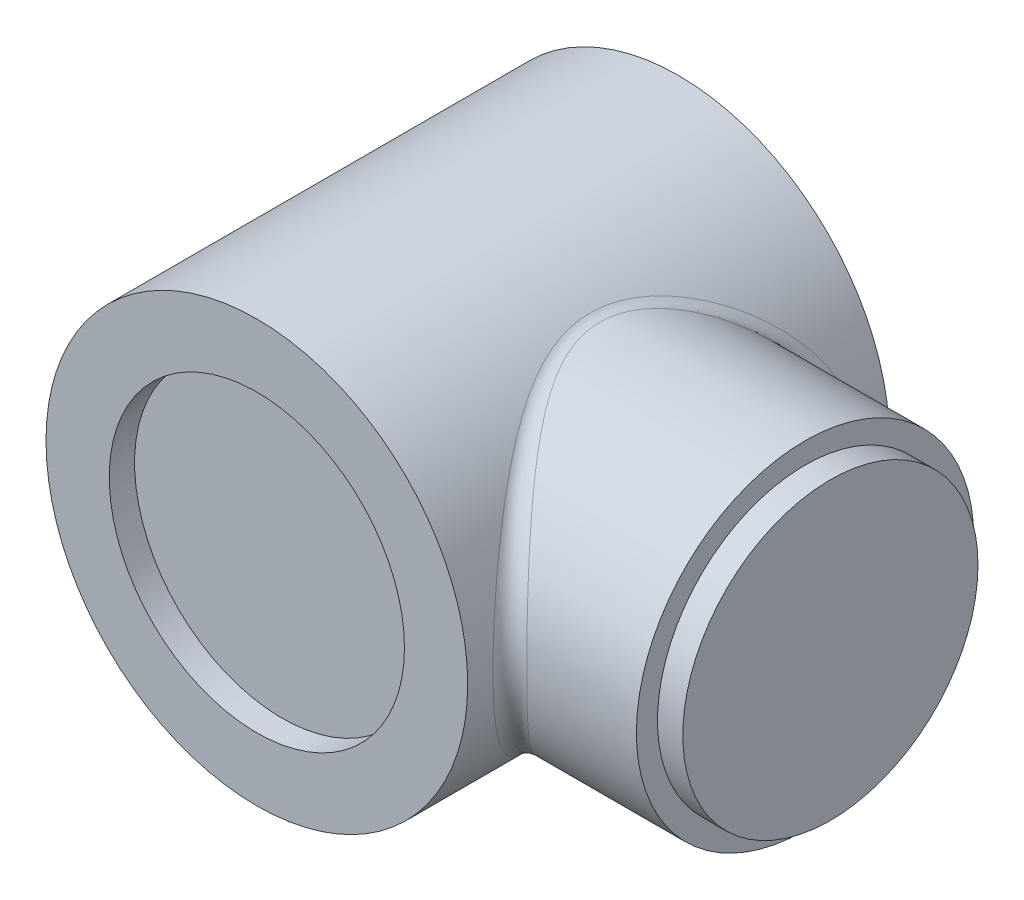
from build123d import *

# Parameters (mm, degrees)
SKETCH1_R           = 25
BOSS_EXTRUDE1_DEPTH = 25
SKETCH2_R           = 17.5
CUT_EXTRUDE1_DEPTH  = 3
SKETCH3_R           = 20
BOSS_EXTRUDE2_DEPTH = 40
SKETCH4_R           = 17.5
BOSS_EXTRUDE3_DEPTH = 3
FILLET1_R           = 2


with BuildPart() as part:
    # Sketch1 → Boss-Extrude1 (new body, symmetric)
    with BuildSketch(Plane.XY):
        Circle(SKETCH1_R)
    extrude(amount=BOSS_EXTRUDE1_DEPTH, both=True)

    # Sketch2 → Cut-Extrude1 (cut)
    with BuildSketch(Plane.XY.offset(25)):
        Circle(SKETCH2_R)
    cut_extrude1 = extrude(amount=-CUT_EXTRUDE1_DEPTH, mode=Mode.SUBTRACT)

    # Mirror1: Cut-Extrude1 across plane
    add(cut_extrude1.mirror(Plane.XY), mode=Mode.SUBTRACT)

    # Sketch3 → Boss-Extrude2 (add)
    with BuildSketch(Plane(origin=(0, 0, 0), x_dir=(0, 0, -1), z_dir=(1, 0, 0))):
        Circle(SKETCH3_R)
    extrude(amount=BOSS_EXTRUDE2_DEPTH)

    # Sketch4 → Boss-Extrude3 (add)
    with BuildSketch(Plane(origin=(40, 0, 0), x_dir=(0, 0, -1), z_dir=(1, 0, 0))):
        Circle(SKETCH4_R)
    extrude(amount=BOSS_EXTRUDE3_DEPTH)

    # Fillet1
    fillet1_edges = [part.edges().sort_by_distance(p)[0] for p in [
        (15, 20, 0),
    ]]
    fillet(fillet1_edges, radius=FILLET1_R)


solid = part.part
